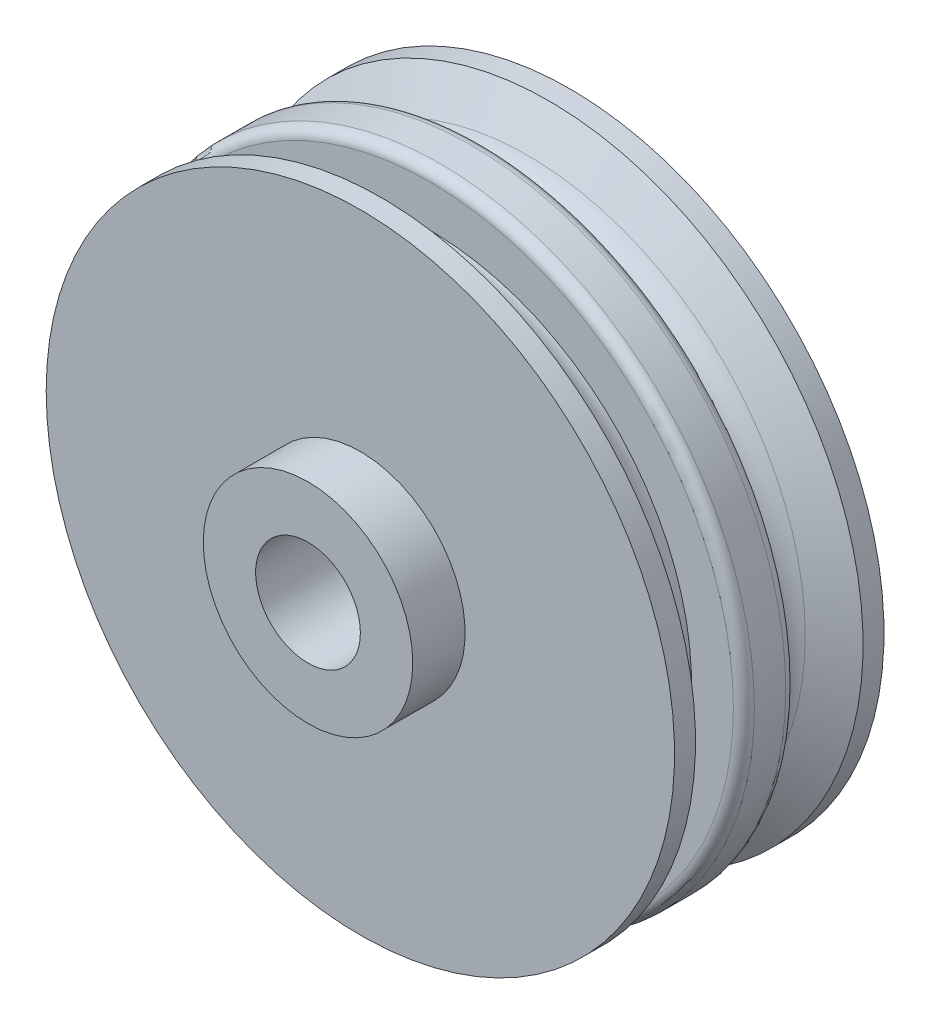
from build123d import *

# Parameters (mm, degrees)
SKETCH1_R           = 10
SKETCH1_R_2         = 5
BOSS_EXTRUDE1_DEPTH = 30
FILLET1_R           = 3
BOSS_EXTRUDE2_START = -5
SKETCH5_R           = 30
SKETCH5_R_2         = 25
BOSS_EXTRUDE2_DEPTH = 5
FILLET2_R           = 1


with BuildPart() as part:
    # Sketch1 → Boss-Extrude1 (new body)
    with BuildSketch(Plane.XY):
        Circle(SKETCH1_R)
        Circle(SKETCH1_R_2, mode=Mode.SUBTRACT)
    extrude(amount=BOSS_EXTRUDE1_DEPTH)

    # Sketch4 → Revolve1 (revolve)
    with BuildSketch(Plane(origin=(0, 0, 0), x_dir=(1, 0, 0), z_dir=(0, 1, 0))):
        Polygon((30, -5), (10, -5), (10, -25), (30, -25), (30, -23), (25, -20.113248654), (25, -9.886751346), (30, -7), align=None)
    revolve(axis=Axis((0, 0, 0), (0, 0, 1)))

    # Fillet1
    fillet1_edges = [part.edges().sort_by_distance(p)[0] for p in [
        (-25, 0, 20.113248654),
        (-25, 0, 9.886751346),
    ]]
    fillet(fillet1_edges, radius=FILLET1_R)

    # Sketch5 → Boss-Extrude2 (add)
    with BuildSketch(Plane.XY.offset(18.381197846).offset(BOSS_EXTRUDE2_START)):
        Circle(SKETCH5_R)
        Circle(SKETCH5_R_2, mode=Mode.SUBTRACT)
    extrude(amount=BOSS_EXTRUDE2_DEPTH)

    # Fillet2
    fillet2_edges = [part.edges().sort_by_distance(p)[0] for p in [
        (-30, 0, 18.381197846),
        (-30, 0, 13.381197846),
    ]]
    fillet(fillet2_edges, radius=FILLET2_R)


solid = part.part
